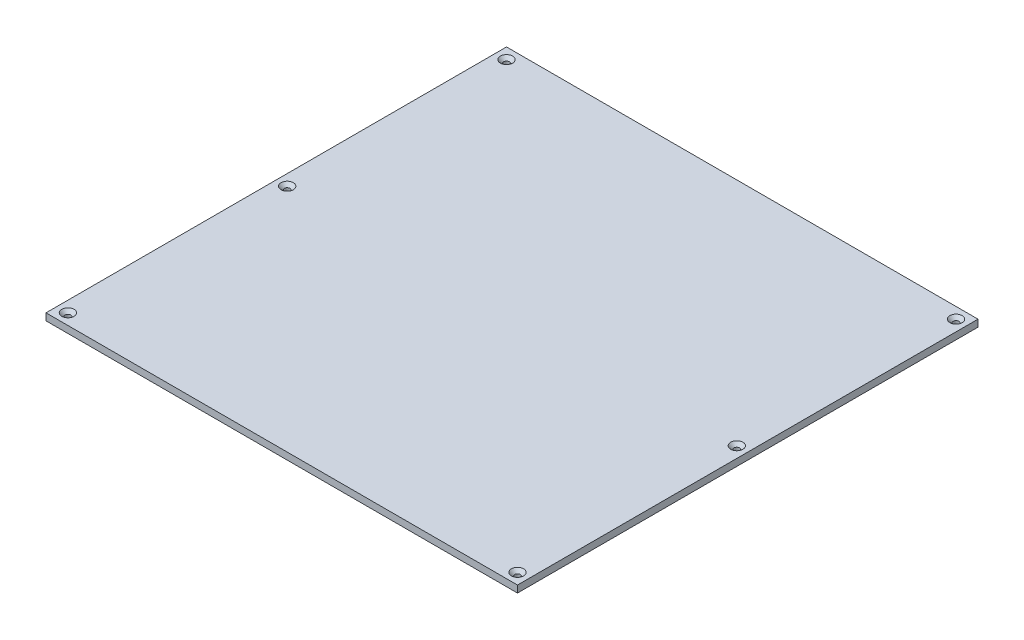
from build123d import *

# Parameters (mm, degrees)
SKETCH2_W           = 430
SKETCH2_H           = 420
SKETCH2_R           = 2.6
BOSS_EXTRUDE1_DEPTH = 3.175
CHAMFER1_SIZE       = 3


with BuildPart() as part:
    # Sketch2 → Boss-Extrude1 (new, symmetric)
    with BuildSketch(Plane(origin=(0, 0, 0), x_dir=(1, 0, 0), z_dir=(0, 1, 0))):
        Rectangle(SKETCH2_W, SKETCH2_H)
        with Locations((-205, 200)):
            Circle(SKETCH2_R, mode=Mode.SUBTRACT)
        with Locations((205, 200)):
            Circle(SKETCH2_R, mode=Mode.SUBTRACT)
        with Locations((205, -200)):
            Circle(SKETCH2_R, mode=Mode.SUBTRACT)
        with Locations((-205, -200)):
            Circle(SKETCH2_R, mode=Mode.SUBTRACT)
        with Locations((-205, 0)):
            Circle(SKETCH2_R, mode=Mode.SUBTRACT)
        with Locations((205, 0)):
            Circle(SKETCH2_R, mode=Mode.SUBTRACT)
    extrude(amount=BOSS_EXTRUDE1_DEPTH, both=True)

    # Chamfer1
    chamfer1_edges = [part.edges().sort_by_distance(p)[0] for p in [
        (-207.6, 3.175, 0),
        (202.4, 3.175, 0),
        (202.4, 3.175, -200),
        (202.4, 3.175, 200),
        (-207.6, 3.175, 200),
        (-207.6, 3.175, -200),
    ]]
    chamfer(chamfer1_edges, length=CHAMFER1_SIZE)


solid = part.part
